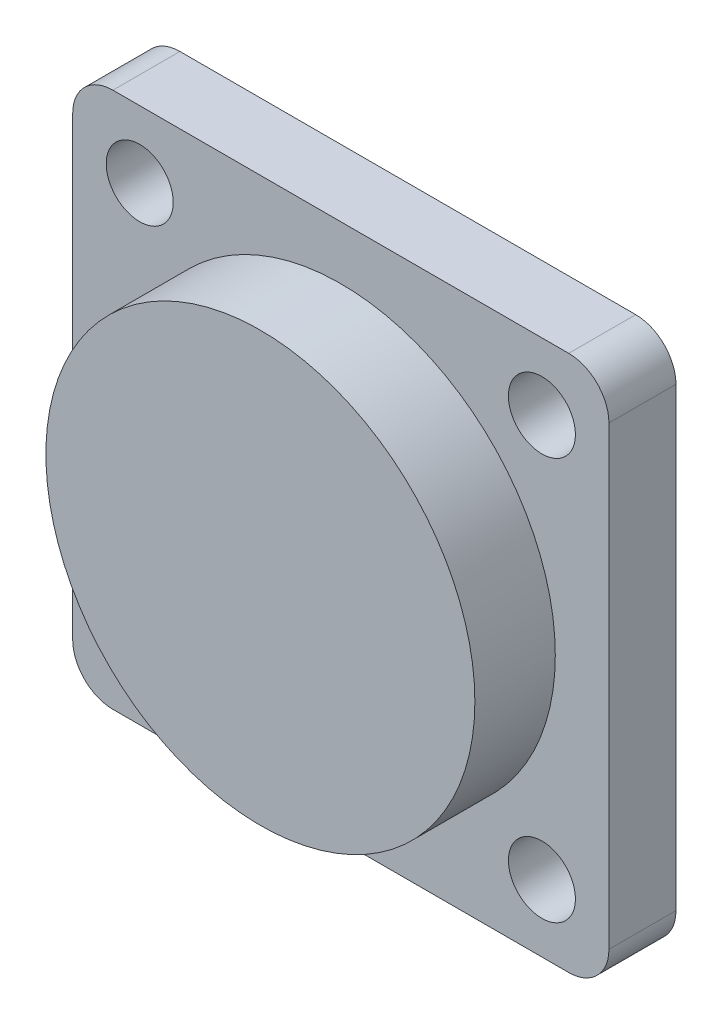
from build123d import *

# Parameters (mm, degrees)
SKETCH1_W           = 40
SKETCH1_H           = 40
SKETCH1_R           = 2.5
BOSS_EXTRUDE1_DEPTH = 5
SKETCH2_R           = 16
BOSS_EXTRUDE2_DEPTH = 6
FILLET2_R           = 3


with BuildPart() as part:
    # Sketch1 → Boss-Extrude1 (new body)
    with BuildSketch(Plane.XY):
        Rectangle(SKETCH1_W, SKETCH1_H)
        with Locations((-15, 15)):
            Circle(SKETCH1_R, mode=Mode.SUBTRACT)
        with Locations((15, 15)):
            Circle(SKETCH1_R, mode=Mode.SUBTRACT)
        with Locations((15, -15)):
            Circle(SKETCH1_R, mode=Mode.SUBTRACT)
        with Locations((-15, -15)):
            Circle(SKETCH1_R, mode=Mode.SUBTRACT)
    extrude(amount=BOSS_EXTRUDE1_DEPTH)

    # Sketch2 → Boss-Extrude2 (add)
    with BuildSketch(Plane.XY.offset(5)):
        Circle(SKETCH2_R)
    extrude(amount=BOSS_EXTRUDE2_DEPTH)

    # Fillet2
    fillet2_edges = [part.edges().sort_by_distance(p)[0] for p in [
        (20, -20, 2.5),
        (-20, -20, 2.5),
        (-20, 20, 2.5),
        (20, 20, 2.5),
    ]]
    fillet(fillet2_edges, radius=FILLET2_R)


solid = part.part
